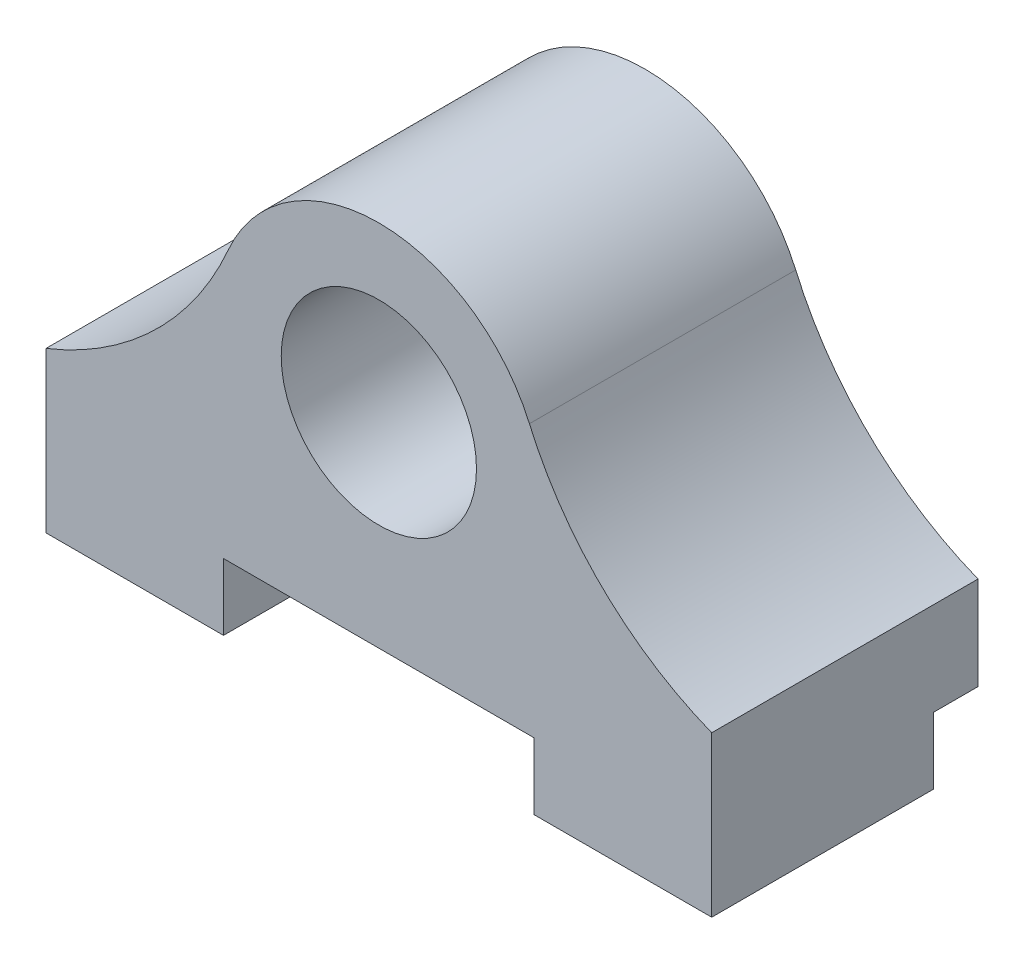
from build123d import *

# Parameters (mm, degrees)
SKETCH1_R               = 4.4
BOSS_EXTRUDE1_DEPTH     = 10
SKETCH1_2_R             = 4.4
BOSS_EXTRUDE2_DEPTH     = 2
SKETCH3_W               = 30
SKETCH3_H               = 12
BOSS_EXTRUDE4_DEPTH     = 7.2
CUT_EXTRUDE2_START      = -12.2
SKETCH2_R               = 1.65
CUT_EXTRUDE2_DEPTH      = 8
SKETCH5_W               = 30
SKETCH5_H               = 3
CUT_EXTRUDE3_DEPTH      = 23.756098084
CUT_EXTRUDE3_DEPTH_BACK = 2
SKETCH6_W               = 14
SKETCH6_H               = 3
CUT_EXTRUDE4_DEPTH      = 23.756098084
CUT_EXTRUDE4_DEPTH_BACK = 23.756098084


with BuildPart() as part:
    # Sketch1 → Boss-Extrude1 (new body)
    with BuildSketch(Plane.XY):
        with BuildLine():
            Line((-15, -5), (15, -5))
            ThreePointArc((15, -5), (10.104984149, -1.836764635), (6.785093744, 2.953388374))
            ThreePointArc((6.785093744, 2.953388374), (0, 7.4), (-6.785093744, 2.953388374))
            ThreePointArc((-6.785093744, 2.953388374), (-10.104984149, -1.836764635), (-15, -5))
        make_face()
        Circle(SKETCH1_R, mode=Mode.SUBTRACT)
    extrude(amount=BOSS_EXTRUDE1_DEPTH)

    # Sketch1_2 → Boss-Extrude2 (add)
    with BuildSketch(Plane.XY):
        with BuildLine():
            ThreePointArc((-6.785093744, 2.953388374), (0, 7.4), (6.785093744, 2.953388374))
            ThreePointArc((6.785093744, 2.953388374), (10.104984149, -1.836764635), (15, -5))
            Line((15, -5), (-15, -5))
            ThreePointArc((-15, -5), (-10.104984149, -1.836764635), (-6.785093744, 2.953388374))
        make_face()
        Circle(SKETCH1_2_R, mode=Mode.SUBTRACT)
        Circle(SKETCH1_2_R)
    extrude(amount=-BOSS_EXTRUDE2_DEPTH)

    # Sketch3 → Boss-Extrude4 (add)
    with BuildSketch(Plane.XZ.offset(5)):
        with Locations((0, 4)):
            Rectangle(SKETCH3_W, SKETCH3_H)
    extrude(amount=BOSS_EXTRUDE4_DEPTH)

    # Sketch2 → Cut-Extrude2 (cut)
    with BuildSketch(Plane(origin=(0, 0, 0), x_dir=(1, 0, 0), z_dir=(0, 1, 0)).offset(CUT_EXTRUDE2_START)):
        with Locations(Location((-11.5, -4, 0), (0, 0, 90))):
            Circle(SKETCH2_R)
        with Locations(Location((11.5, -4, 0), (0, 0, 90))):
            Circle(SKETCH2_R)
    extrude(amount=CUT_EXTRUDE2_DEPTH, mode=Mode.SUBTRACT)

    # Sketch5 → Cut-Extrude3 (cut, two sides)
    with BuildSketch(Plane(origin=(0, 0, -2), x_dir=(-1, 0, 0), z_dir=(0, 0, -1))) as cut_extrude3_sk:
        with Locations((0, -10.7)):
            Rectangle(SKETCH5_W, SKETCH5_H)
    extrude(amount=CUT_EXTRUDE3_DEPTH, mode=Mode.SUBTRACT)
    extrude(cut_extrude3_sk.sketch, amount=-CUT_EXTRUDE3_DEPTH_BACK, mode=Mode.SUBTRACT)

    # Sketch6 → Cut-Extrude4 (cut, two sides)
    with BuildSketch(Plane.XY.offset(10)) as cut_extrude4_sk:
        with Locations((0, -10.7)):
            Rectangle(SKETCH6_W, SKETCH6_H)
    extrude(amount=CUT_EXTRUDE4_DEPTH, mode=Mode.SUBTRACT)
    extrude(cut_extrude4_sk.sketch, amount=-CUT_EXTRUDE4_DEPTH_BACK, mode=Mode.SUBTRACT)


solid = part.part
